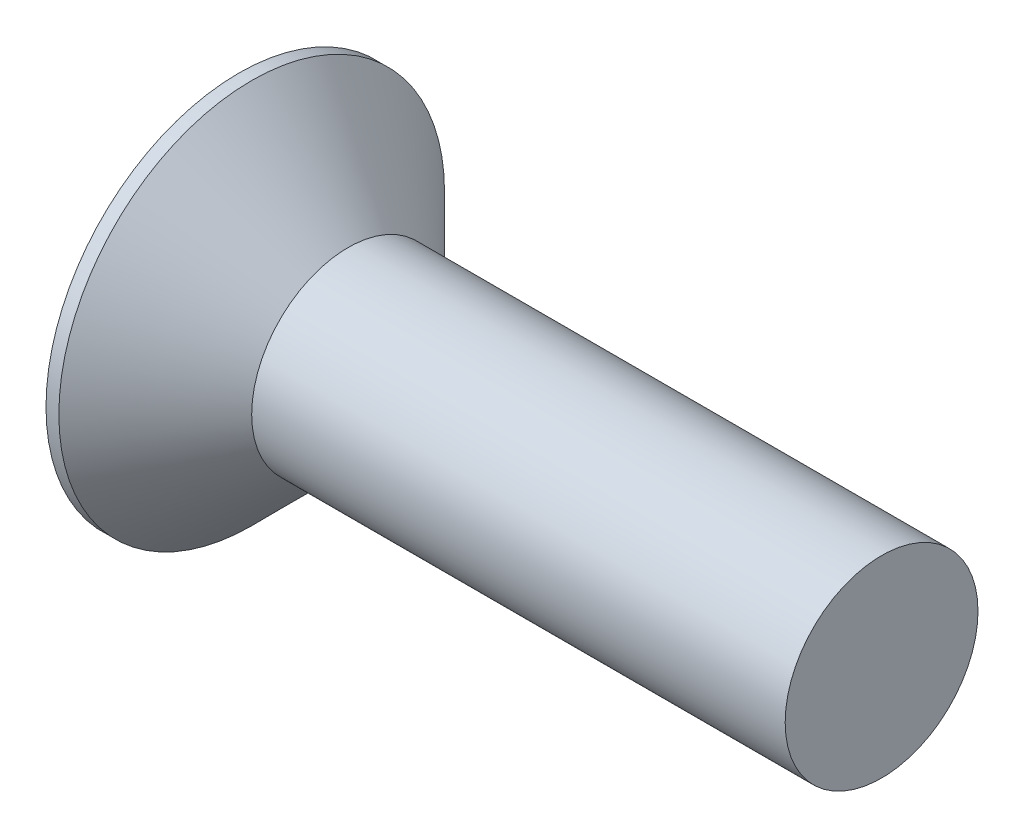
from build123d import *

# Parameters (mm, degrees)
CUT_EXTRUDE1_DEPTH = 0.85


with BuildPart() as part:
    # Sketch1 → Revolve1 (revolve)
    with BuildSketch(Plane.XY):
        Polygon((-1.7, 0), (-1.7, 3), (-1.5, 3), (0, 1.5), (8.3, 1.5), (8.3, 0), align=None)
    revolve(axis=Axis((-1.7, 0, 0), (1, 0, 0)))

    # Sketch2 → Cut-Revolve2 (revolve, cut)
    with BuildSketch(Plane.XY):
        Polygon((-0.249139381, 0), (-0.85, 1), (-1.7, 1), (-1.7, 0), align=None)
    revolve(axis=Axis((-0.249139381, 0, 0), (-1, 0, 0)), mode=Mode.SUBTRACT)

    # Sketch3 → Cut-Extrude1 (cut)
    with BuildSketch(Plane.ZY.offset(1.7)):
        Polygon((0, 1.154700538), (-1, 0.577350269), (-1, -0.577350269), (0, -1.154700538), (1, -0.577350269), (1, 0.577350269), align=None)
    extrude(amount=-CUT_EXTRUDE1_DEPTH, mode=Mode.SUBTRACT)


solid = part.part
